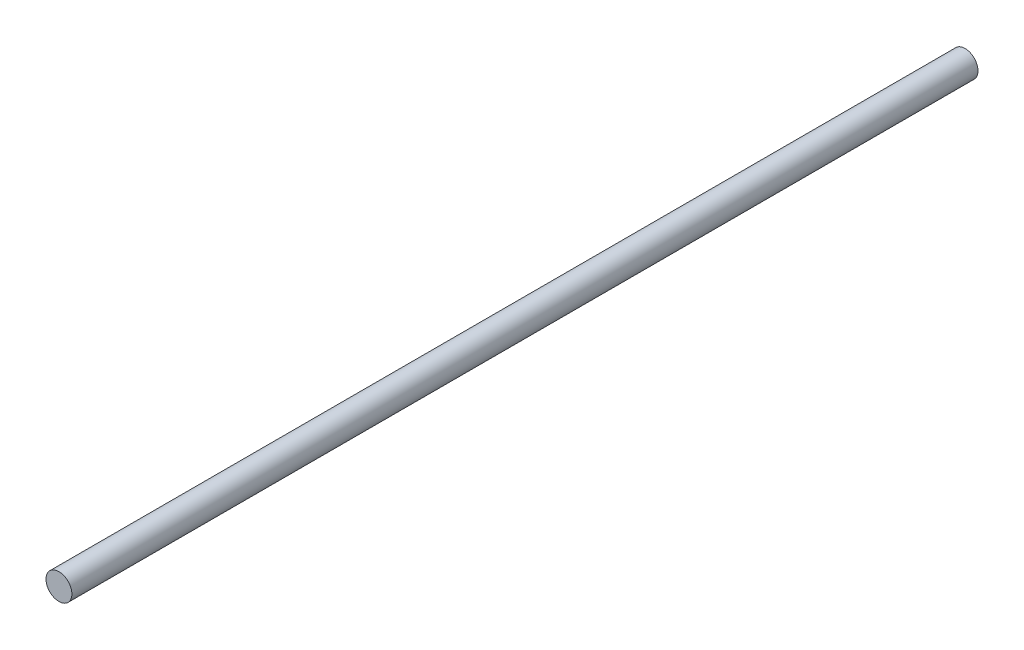
from build123d import *

# Parameters (mm, degrees)
ESBO_O1_R                = 4
RESSALTO_EXTRUS_O1_DEPTH = 280


with BuildPart() as part:
    # Esboço1 → Ressalto-extrusão1 (new body)
    with BuildSketch(Plane.XY):
        Circle(ESBO_O1_R)
    extrude(amount=RESSALTO_EXTRUS_O1_DEPTH)


solid = part.part
